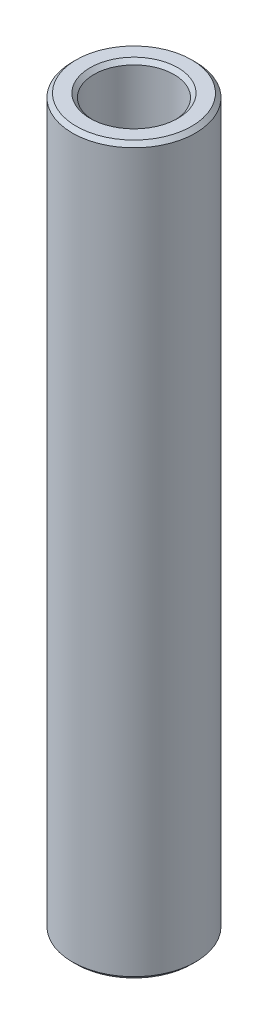
from build123d import *

# Parameters (mm, degrees)
SKETCH1_W     = 0.7
SKETCH1_H     = 23.57374
CHAMFER1_SIZE = 0.127


with BuildPart() as part:
    # Sketch1 → Revolve1 (revolve)
    with BuildSketch(Plane.XY):
        with Locations((1.65, 0)):
            Rectangle(SKETCH1_W, SKETCH1_H)
    revolve(axis=Axis((0, 9.615558323, 0), (0, -1, 0)))

    # Chamfer1
    chamfer1_edges = [part.edges().sort_by_distance(p)[0] for p in [
        (-1.3, 11.78687, 0),
        (-2, 11.78687, 0),
        (-2, -11.78687, 0),
        (-1.3, -11.78687, 0),
    ]]
    chamfer(chamfer1_edges, length=CHAMFER1_SIZE)


solid = part.part
